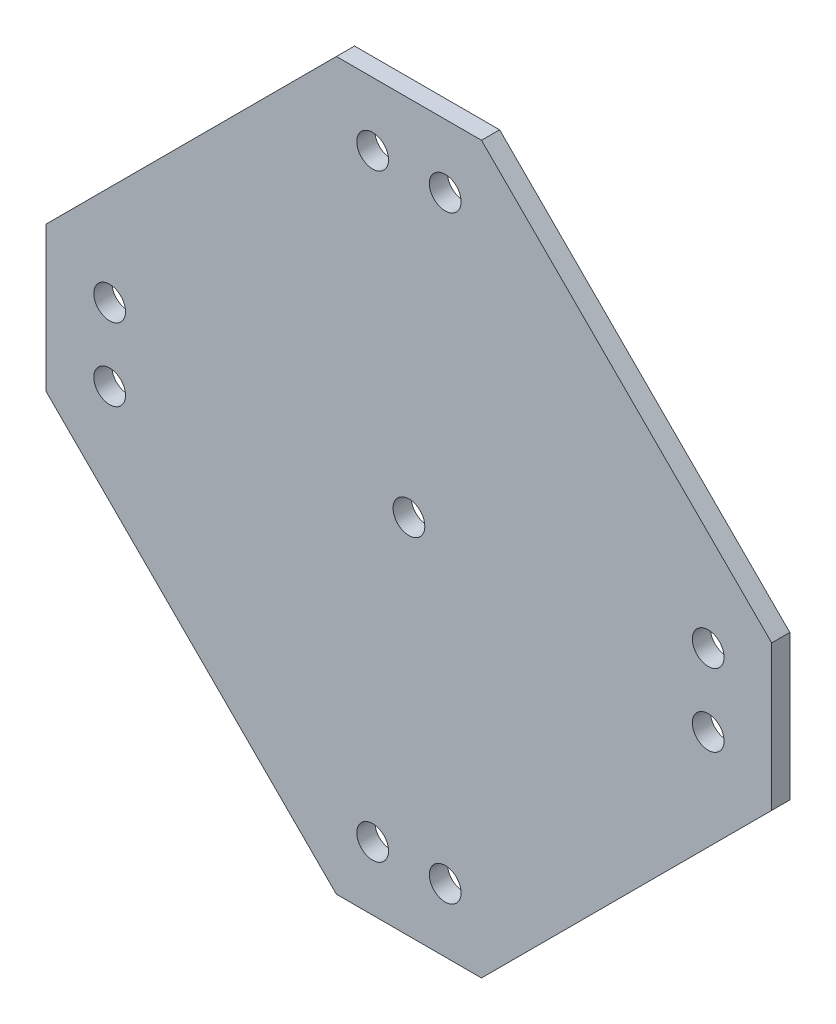
from build123d import *

# Parameters (mm, degrees)
BOSS_EXTRUDE1_DEPTH = 2
CUT_EXTRUDE1_START  = -3
SKETCH2_R           = 1.75
CUT_EXTRUDE1_DEPTH  = 4
CIRPATTERN1_COUNT   = 4


with BuildPart() as part:
    # Sketch1 → Boss-Extrude1 (new body)
    with BuildSketch(Plane.XY):
        Polygon((-8, 40), (8, 40), (40, 8), (40, -8), (8, -40), (-8, -40), (-40, -8), (-40, 8), align=None)
    extrude(amount=BOSS_EXTRUDE1_DEPTH)

    # Sketch2 → Cut-Extrude1 (cut)
    with BuildSketch(Plane.XY.offset(2).offset(CUT_EXTRUDE1_START)):
        with Locations((-4, 33)):
            Circle(SKETCH2_R)
        with Locations((4, 33)):
            Circle(SKETCH2_R)
        Circle(SKETCH2_R)
    cut_extrude1 = extrude(amount=CUT_EXTRUDE1_DEPTH, mode=Mode.SUBTRACT)

    # CirPattern1: Cut-Extrude1 ×4 about axis
    cirpattern1_axis = Axis((0, 0, 0), (0, 0, 1))
    for i in range(1, CIRPATTERN1_COUNT):
        add(cut_extrude1.rotate(cirpattern1_axis, i * 360 / CIRPATTERN1_COUNT), mode=Mode.SUBTRACT)


solid = part.part
